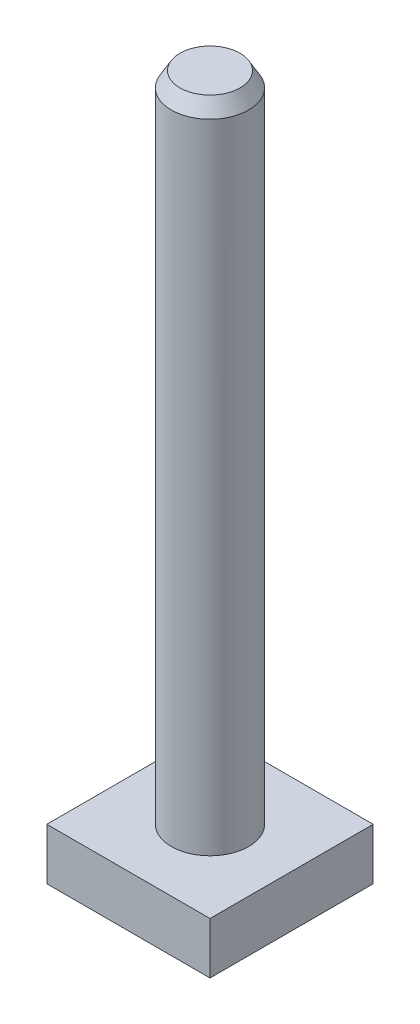
from build123d import *

# Parameters (mm, degrees)
SKETCH1_W           = 4.5
SKETCH1_H           = 76
SKETCH2_W           = 19
SKETCH2_H           = 19
BOSS_EXTRUDE1_DEPTH = 6
CHAMFER2_SIZE       = 1
CHAMFER2_SIZE2      = 1.732050808


with BuildPart() as part:
    # Sketch1 → Revolve1 (revolve)
    with BuildSketch(Plane.XY, mode=Mode.PRIVATE) as revolve1_sk:
        with Locations((2.25, 38)):
            Rectangle(SKETCH1_W, SKETCH1_H)
    revolve(revolve1_sk.sketch.rotate(Axis((0, 0, 0), (0, 1, 0)), 90), axis=Axis((0, 0, 0), (0, 1, 0)))  # turned: the seam where the file's is

    # Sketch2 → Boss-Extrude1 (add)
    with BuildSketch(Plane(origin=(0, 0, 0), x_dir=(1, 0, 0), z_dir=(0, 1, 0))):
        Rectangle(SKETCH2_W, SKETCH2_H)
    extrude(amount=-BOSS_EXTRUDE1_DEPTH)

    # Chamfer2
    chamfer2_edges = [part.edges().sort_by_distance(p)[0] for p in [
        (0, 76, 4.5),
    ]]
    chamfer2_side = [part.faces().sort_by_distance(p)[0] for p in [
        (0, 76, 0),
    ]]
    chamfer(chamfer2_edges, length=CHAMFER2_SIZE, length2=CHAMFER2_SIZE2, reference=chamfer2_side[0])


solid = part.part
